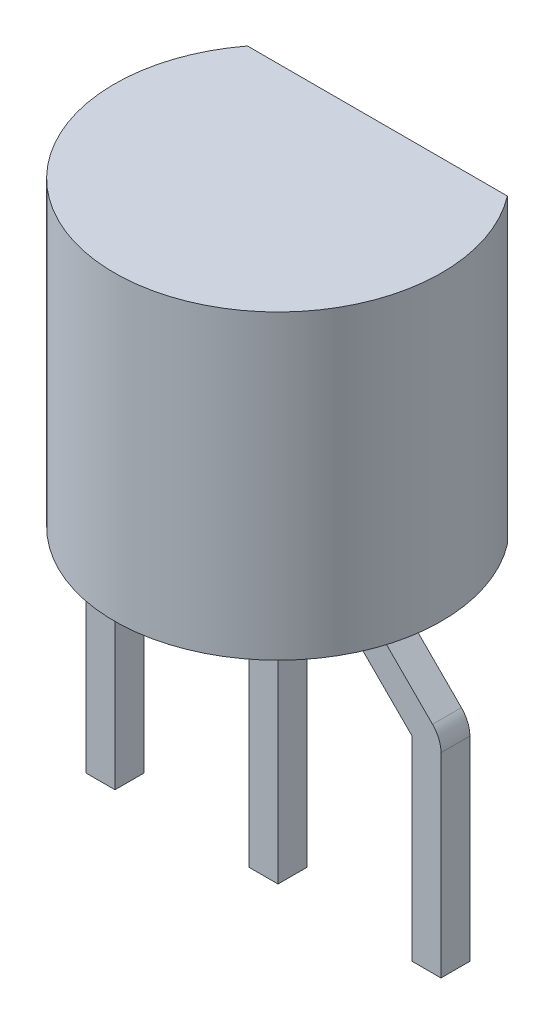
from build123d import *

# Parameters (mm, degrees)
SKETCH3_R       = 2.55
EXTRUDE2_DEPTH  = 4.7
EXTRUDE3_DEPTH  = 6.924103308
SKETCH13_W      = 0.45
SKETCH13_H      = 0.45
EXTRUDE8_DEPTH  = 0.1
SKETCH12_W      = 0.45
SKETCH12_H      = 0.45
EXTRUDE9_DEPTH  = 0.1
SKETCH11_W      = 0.45
SKETCH11_H      = 0.45
EXTRUDE10_DEPTH = 1.598630162
SKETCH32_W      = 0.45
SKETCH32_H      = 0.45
REVOLVE4_ANGLE  = 45
SKETCH34_W      = 0.45
SKETCH34_H      = 0.45
EXTRUDE12_DEPTH = 1.61
SKETCH36_W      = 0.45
SKETCH36_H      = 0.45
REVOLVE5_ANGLE  = 45
SKETCH37_W      = 0.45
SKETCH37_H      = 0.45
EXTRUDE13_DEPTH = 3.04
SKETCH38_W      = 0.45
SKETCH38_H      = 0.45
REVOLVE6_ANGLE  = 45
SKETCH39_W      = 0.45
SKETCH39_H      = 0.45
EXTRUDE14_DEPTH = 1.61
SKETCH40_W      = 0.45
SKETCH40_H      = 0.45
REVOLVE7_ANGLE  = 45
SKETCH41_W      = 0.45
SKETCH41_H      = 0.45
EXTRUDE15_DEPTH = 3.04
SKETCH42_W      = 0.45
SKETCH42_H      = 0.45
EXTRUDE16_DEPTH = 3


with BuildPart() as part:
    # Sketch3 → Extrude2 (new body)
    with BuildSketch(Plane(origin=(0, 0, 0), x_dir=(1, 0, 0), z_dir=(0, 1, 0))):
        Circle(SKETCH3_R)
    extrude(amount=EXTRUDE2_DEPTH)

    # Sketch3_3 → Extrude3 (cut, through all)
    with BuildSketch(Plane(origin=(0, 0, 0), x_dir=(1, 0, 0), z_dir=(0, 1, 0))):
        with BuildLine():
            ThreePointArc((2.024845673, 1.55), (0, 2.55), (-2.024845673, 1.55))
            Line((-2.024845673, 1.55), (2.024845673, 1.55))
        make_face()
    extrude(amount=EXTRUDE3_DEPTH, mode=Mode.SUBTRACT)

    # Sketch13 → Extrude8 (add)
    with BuildSketch(Plane.XZ):
        with Locations((1.27, 0)):
            Rectangle(SKETCH13_W, SKETCH13_H)
    extrude(amount=EXTRUDE8_DEPTH)

    # Sketch12 → Extrude9 (add)
    with BuildSketch(Plane.XZ):
        with Locations((-1.27, 0)):
            Rectangle(SKETCH12_W, SKETCH12_H)
    extrude(amount=EXTRUDE9_DEPTH)

    # Sketch11 → Extrude10 (add)
    with BuildSketch(Plane.XZ):
        Rectangle(SKETCH11_W, SKETCH11_H)
    extrude(amount=EXTRUDE10_DEPTH)

    # Sketch32 → Revolve4 (revolve)
    with BuildSketch(Plane.XZ.offset(0.1)):
        with Locations((-1.27, 0)):
            Rectangle(SKETCH32_W, SKETCH32_H)
    revolve(axis=Axis((-1.495, -0.1, 0.225), (0, 0, -1)), revolution_arc=REVOLVE4_ANGLE)

    # Sketch34 → Extrude12 (add)
    with BuildSketch(Plane(origin=(-0.7975, -0.7975, 0), x_dir=(0, 0, 1), z_dir=(-0.7071067811865488, -0.7071067811865462, 0))):
        with Locations((0, 0.76141396)):
            Rectangle(SKETCH34_W, SKETCH34_H)
    extrude(amount=EXTRUDE12_DEPTH)

    # Sketch36 → Revolve5 (revolve)
    with BuildSketch(Plane(origin=(-1.935941918, -1.935941918, 0), x_dir=(0, 0, 1), z_dir=(-0.7071067811865487, -0.7071067811865464, 0))):
        with Locations((0, 0.76141396)):
            Rectangle(SKETCH36_W, SKETCH36_H)
    revolve(axis=Axis((-2.315243866, -1.556639969, -0.225), (0, 0, 1)), revolution_arc=REVOLVE5_ANGLE)

    # Sketch37 → Extrude13 (add)
    with BuildSketch(Plane.XZ.offset(1.556639969)):
        with Locations((-2.540243866, 0)):
            Rectangle(SKETCH37_W, SKETCH37_H)
    extrude(amount=EXTRUDE13_DEPTH)

    # Sketch38 → Revolve6 (revolve)
    with BuildSketch(Plane.XZ.offset(0.1)):
        with Locations((1.27, 0)):
            Rectangle(SKETCH38_W, SKETCH38_H)
    revolve(axis=Axis((1.495, -0.1, 0.225), (0, 0, 1)), revolution_arc=REVOLVE6_ANGLE)

    # Sketch39 → Extrude14 (add)
    with BuildSketch(Plane(origin=(0.7975, -0.7975, 0), x_dir=(0, 0, -1), z_dir=(0.7071067811865488, -0.7071067811865462, 0))):
        with Locations((0, 0.76141396)):
            Rectangle(SKETCH39_W, SKETCH39_H)
    extrude(amount=EXTRUDE14_DEPTH)

    # Sketch40 → Revolve7 (revolve)
    with BuildSketch(Plane(origin=(1.935941918, -1.935941918, 0), x_dir=(0, 0, -1), z_dir=(0.7071067811865488, -0.7071067811865464, 0))):
        with Locations((0, 0.76141396)):
            Rectangle(SKETCH40_W, SKETCH40_H)
    revolve(axis=Axis((2.315243866, -1.556639969, 0.225), (0, 0, -1)), revolution_arc=REVOLVE7_ANGLE)

    # Sketch41 → Extrude15 (add)
    with BuildSketch(Plane.XZ.offset(1.556639969)):
        with Locations((2.540243866, 0)):
            Rectangle(SKETCH41_W, SKETCH41_H)
    extrude(amount=EXTRUDE15_DEPTH)

    # Sketch42 → Extrude16 (add)
    with BuildSketch(Plane.XZ.offset(1.598630162)):
        Rectangle(SKETCH42_W, SKETCH42_H)
    extrude(amount=EXTRUDE16_DEPTH)


solid = part.part
